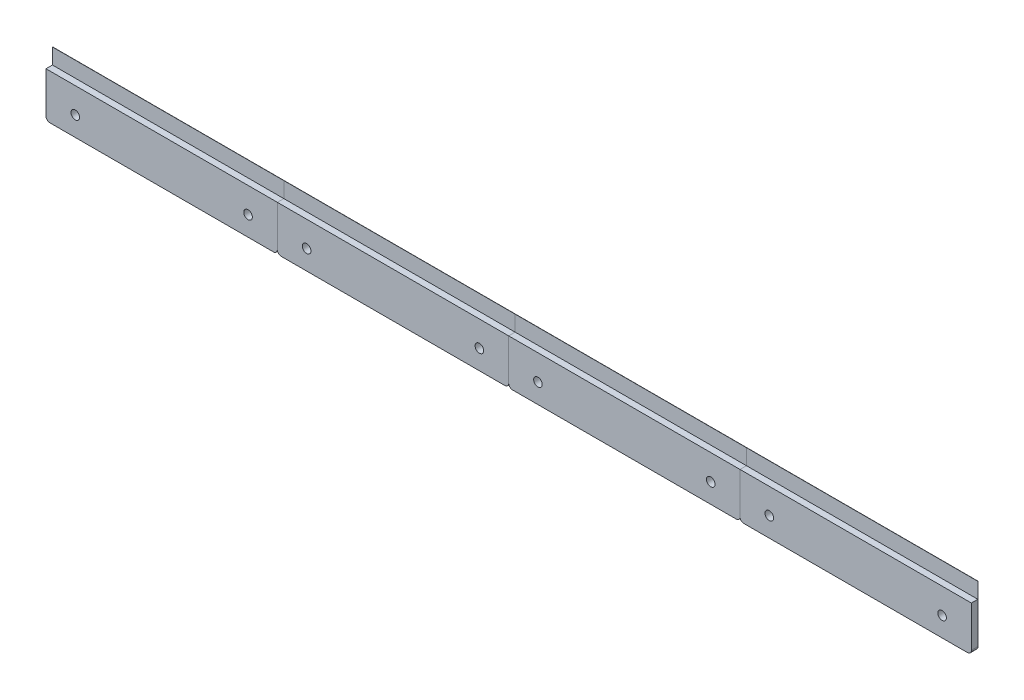
from build123d import *

# Parameters (mm, degrees)
SKETCH1_W           = 118.5
SKETCH1_H           = 23
SKETCH1_R           = 2.2
BOSS_EXTRUDE1_DEPTH = 4
SKETCH1_3_W         = 118.5
SKETCH1_3_H         = 8
BOSS_EXTRUDE2_DEPTH = 0.7
FILLET2_R           = 2
FILLET3_R           = 2
FILLET5_R           = 2
FILLET6_R           = 2
CHAMFER6_SIZE       = 0.6
CHAMFER5_SIZE       = 0.6
CHAMFER3_SIZE       = 0.6
CHAMFER4_SIZE       = 0.6


with BuildPart() as part:
    # Sketch1 → Boss-Extrude1 (new body)
    with BuildSketch(Plane.XY):
        with Locations((-59.25, 11.5)):
            Rectangle(SKETCH1_W, SKETCH1_H)
        with Locations((-15, 10)):
            Circle(SKETCH1_R, mode=Mode.SUBTRACT)
        with Locations((-103.5, 10)):
            Circle(SKETCH1_R, mode=Mode.SUBTRACT)
    extrude(amount=BOSS_EXTRUDE1_DEPTH)

    # Sketch1_3 → Boss-Extrude2 (add)
    with BuildSketch(Plane.XY):
        with Locations((-59.25, 27)):
            Rectangle(SKETCH1_3_W, SKETCH1_3_H)
    extrude(amount=BOSS_EXTRUDE2_DEPTH)


with BuildPart() as body_2:
    # Mirror1: mirrored copy
    add(part.part.mirror(Plane(origin=(0, 0, 4), x_dir=(0, 0, 1), z_dir=(-1, 0, 0))))


with BuildPart() as body_3:
    # Mirror2: mirrored copy
    add(part.part.mirror(Plane(origin=(-118.5, 0, 4), x_dir=(0, 0, 1), z_dir=(-1, 0, 0))))

    # Fillet6
    fillet6_edges = [body_3.edges().sort_by_distance(p)[0] for p in [
        (-237, 0, 2),
        (-118.5, 0, 2),
    ]]
    fillet(fillet6_edges, radius=FILLET6_R)

    # Chamfer5
    chamfer5_edges = [body_3.edges().sort_by_distance(p)[0] for p in [
        (-131.3, 10, 0),
        (-219.8, 10, 0),
        (-177.75, 31, 0),
        (-118.5, 16.5, 0),
        (-177.75, 0, 0),
        (-237, 16.5, 0),
        (-236.414213562, 0.585786438, 0),
        (-119.085786438, 0.585786438, 0),
    ]]
    chamfer(chamfer5_edges, length=CHAMFER5_SIZE)


with BuildPart() as body_4:
    # Mirror2 2: mirrored copy
    add(body_2.part.mirror(Plane(origin=(-118.5, 0, 4), x_dir=(0, 0, 1), z_dir=(-1, 0, 0))))

    # Fillet5
    fillet5_edges = [body_4.edges().sort_by_distance(p)[0] for p in [
        (-237, 0, 2),
        (-355.5, 0, 2),
    ]]
    fillet(fillet5_edges, radius=FILLET5_R)

    # Chamfer6
    chamfer6_edges = [body_4.edges().sort_by_distance(p)[0] for p in [
        (-342.7, 10, 0),
        (-254.2, 10, 0),
        (-296.25, 31, 0),
        (-296.25, 0, 0),
        (-355.5, 16.5, 0),
        (-237, 16.5, 0),
        (-237.585786438, 0.585786438, 0),
        (-354.914213562, 0.585786438, 0),
    ]]
    chamfer(chamfer6_edges, length=CHAMFER6_SIZE)


with BuildPart() as part_1:
    add(part.part)

    # Fillet2
    fillet2_edges = [part_1.edges().sort_by_distance(p)[0] for p in [
        (0, 0, 2),
        (-118.5, 0, 2),
    ]]
    fillet(fillet2_edges, radius=FILLET2_R)

    # Chamfer4
    chamfer4_edges = [part_1.edges().sort_by_distance(p)[0] for p in [
        (-105.7, 10, 0),
        (-17.2, 10, 0),
        (-59.25, 31, 0),
        (0, 16.5, 0),
        (-118.5, 16.5, 0),
        (-59.25, 0, 0),
        (-117.914213562, 0.585786438, 0),
        (-0.585786438, 0.585786438, 0),
    ]]
    chamfer(chamfer4_edges, length=CHAMFER4_SIZE)


with BuildPart() as body_2_1:
    add(body_2.part)

    # Fillet3
    fillet3_edges = [body_2_1.edges().sort_by_distance(p)[0] for p in [
        (0, 0, 2),
        (118.5, 0, 2),
    ]]
    fillet(fillet3_edges, radius=FILLET3_R)

    # Chamfer3
    chamfer3_edges = [body_2_1.edges().sort_by_distance(p)[0] for p in [
        (105.7, 10, 0),
        (17.2, 10, 0),
        (59.25, 31, 0),
        (118.5, 16.5, 0),
        (59.25, 0, 0),
        (0, 16.5, 0),
        (0.585786438, 0.585786438, 0),
        (117.914213562, 0.585786438, 0),
    ]]
    chamfer(chamfer3_edges, length=CHAMFER3_SIZE)


solid = Compound([body_3.part, body_4.part, part_1.part, body_2_1.part])
